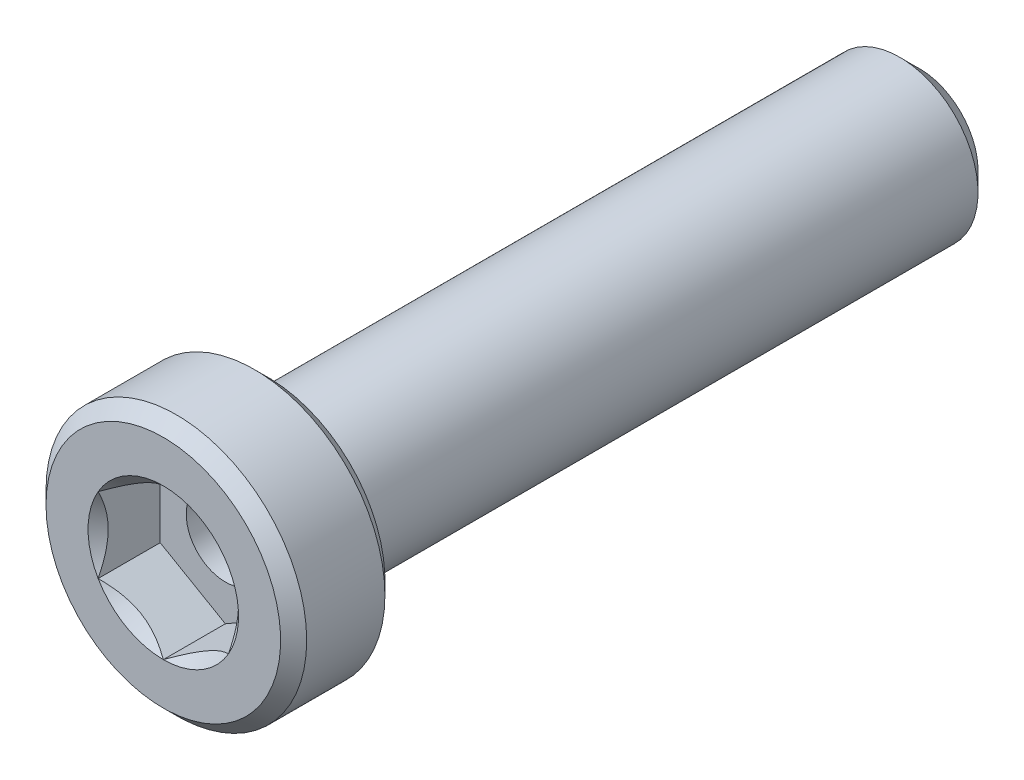
from build123d import *

# Parameters (mm, degrees)
CHAMFER1_SIZE          = 0.5
CUT_EXTRUDE1_DEPTH     = 2.38
SPLIT1_SURFACE_1_BACK  = 33.265
SPLIT1_SURFACE_1_DEPTH = 66.53
SPLIT1_SURFACE_2_BACK  = 33.265
SPLIT1_SURFACE_2_DEPTH = 66.53
CHAMFER2_SIZE          = 0.75


with BuildPart() as part:
    # Sketch1 → Revolve1 (revolve)
    with BuildSketch(Plane.ZY):
        Polygon((0, 3), (0, 0), (29, 0), (29, 5), (25, 5), (25, 3), align=None)
    revolve(axis=Axis((0, 0, 25), (0, 0, 1)))

    # Chamfer1
    chamfer1_edges = [part.edges().sort_by_distance(p)[0] for p in [
        (0, -5, 25),
        (0, -5, 29),
    ]]
    chamfer(chamfer1_edges, length=CHAMFER1_SIZE)

    # Sketch2 → Cut-Extrude1 (cut)
    with BuildSketch(Plane.XY.offset(29)):
        Polygon((0, 2.886751346), (-2.5, 1.443375673), (-2.5, -1.443375673), (0, -2.886751346), (2.5, -1.443375673), (2.5, 1.443375673), align=None)
    extrude(amount=-CUT_EXTRUDE1_DEPTH, mode=Mode.SUBTRACT)

    # Sketch3 → Cut-Revolve1 (revolve, cut)
    with BuildSketch(Plane(origin=(0, 0, 11.32), x_dir=(0, 0, 1), z_dir=(-1, 0, 0))):
        Polygon((13.619461487, 1.5), (12.92, 0), (15.3, 0), (15.3, 1.5), align=None)
    revolve(axis=Axis((0, 0, 26.62), (0, 0, -1)), mode=Mode.SUBTRACT)

    # Cut-Extrude2 cone 1 section (through the dimple's axis) → Cut-Extrude2 (revolve, cut)
    with BuildSketch(Plane(origin=(0, 0, 29), x_dir=(0, -1, 0), z_dir=(1, 0, 0))):
        Polygon((0, 0), (2.886751346, 0), (0, 2.886751346), align=None)
    revolve(axis=Axis((0, 0, 29), (0, 0, -1)), mode=Mode.SUBTRACT)


with BuildPart() as body_2:
    # Split1: the piece behind the surface
    add(part.part)
    # Split1 surface: a surface, the sketch's curves swept straight by 66.53 mm
    with BuildLine(Plane(origin=(0, 0, 0), x_dir=(0, 0, -1), z_dir=(1, 0, 0)).offset(-SPLIT1_SURFACE_1_BACK), mode=Mode.PRIVATE) as split1_surface_1_path:
        Line((-19.5, 3), (-19.5, -3))
    split1_surface_1 = Shell.extrude(split1_surface_1_path.wire(), (1 * SPLIT1_SURFACE_1_DEPTH, 0 * SPLIT1_SURFACE_1_DEPTH, 0 * SPLIT1_SURFACE_1_DEPTH))
    split(bisect_by=split1_surface_1, keep=Keep.BOTTOM)


with BuildPart() as part_1:
    add(part.part)

    # Split1: split by a surface, the side it looks to stays
    # Split1 surface: a surface, the sketch's curves swept straight by 66.53 mm
    with BuildLine(Plane(origin=(0, 0, 0), x_dir=(0, 0, -1), z_dir=(1, 0, 0)).offset(-SPLIT1_SURFACE_2_BACK), mode=Mode.PRIVATE) as split1_surface_2_path:
        Line((-19.5, 3), (-19.5, -3))
    split1_surface_2 = Shell.extrude(split1_surface_2_path.wire(), (1 * SPLIT1_SURFACE_2_DEPTH, 0 * SPLIT1_SURFACE_2_DEPTH, 0 * SPLIT1_SURFACE_2_DEPTH))
    split(bisect_by=split1_surface_2, keep=Keep.TOP)

    # Chamfer2
    chamfer2_edges = [part_1.edges().sort_by_distance(p)[0] for p in [
        (0, -3, 0),
    ]]
    chamfer(chamfer2_edges, length=CHAMFER2_SIZE)


with BuildPart() as body_2_1:
    add(body_2.part)

    # Combine1: union part
    add(part_1.part)


solid = body_2_1.part
